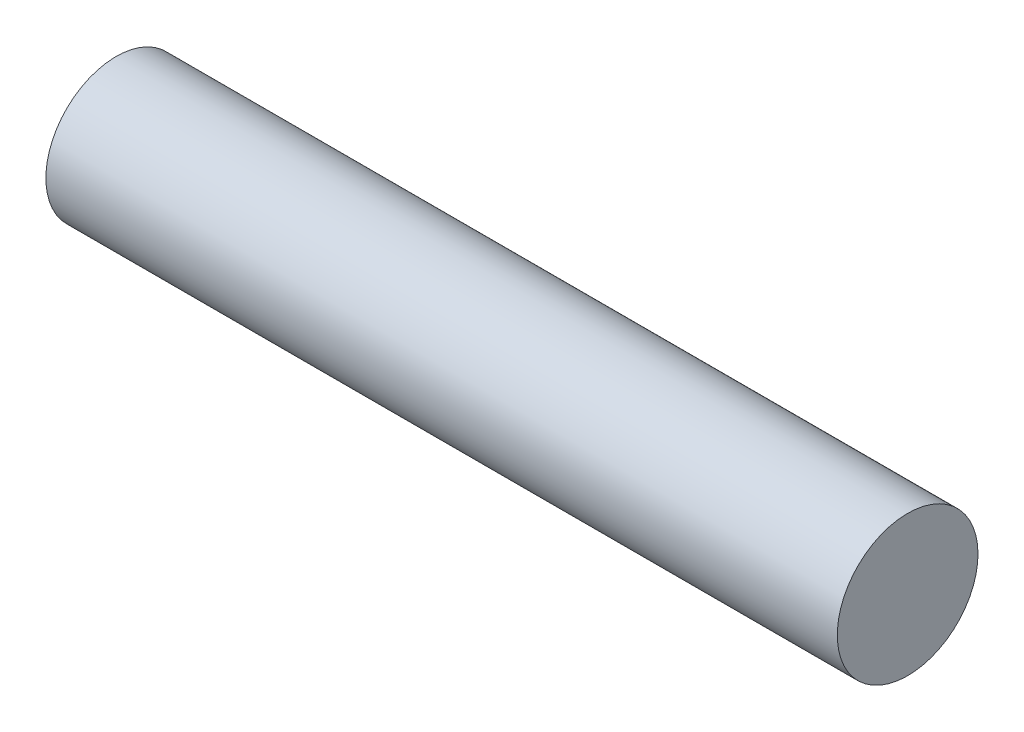
from build123d import *

# Parameters (mm, degrees)
CROQUIS1_R              = 4
SALIENTE_EXTRUIR1_DEPTH = 45


with BuildPart() as part:
    # Croquis1 → Saliente-Extruir1 (new body)
    with BuildSketch(Plane(origin=(0, 0, 0), x_dir=(0, 0, -1), z_dir=(1, 0, 0))):
        Circle(CROQUIS1_R)
    extrude(amount=SALIENTE_EXTRUIR1_DEPTH)


solid = part.part
